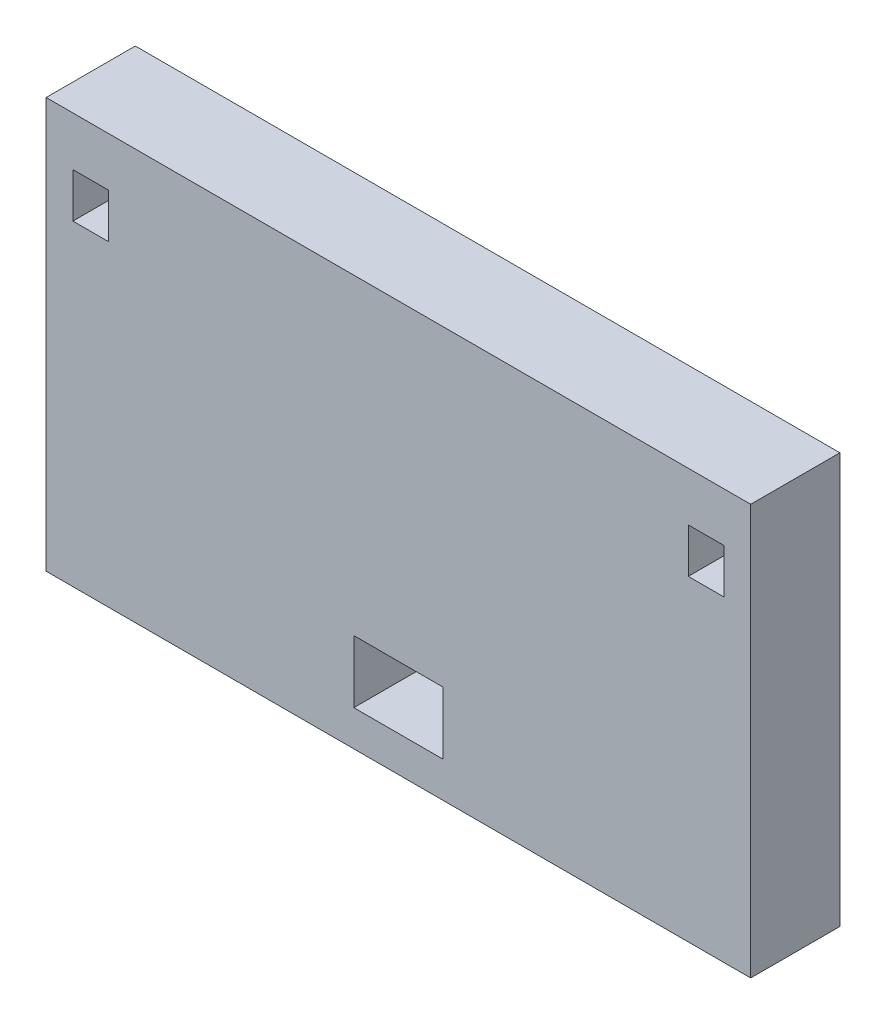
from build123d import *

# Parameters (mm, degrees)
SKETCH1_W           = 79
SKETCH1_H           = 46
SKETCH1_W_2         = 4
SKETCH1_H_2         = 5
SKETCH1_W_3         = 10
SKETCH1_H_3         = 7
BOSS_EXTRUDE1_DEPTH = 10


with BuildPart() as part:
    # Sketch1 → Boss-Extrude1 (new body)
    with BuildSketch(Plane.XY):
        with Locations((0, 20.611542264)):
            Rectangle(SKETCH1_W, SKETCH1_H)
        with Locations((-34.5, 35.611542264)):
            Rectangle(SKETCH1_W_2, SKETCH1_H_2, mode=Mode.SUBTRACT)
        with Locations((0, 5.111542264)):
            Rectangle(SKETCH1_W_3, SKETCH1_H_3, mode=Mode.SUBTRACT)
        with Locations((34.5, 35.611542264)):
            Rectangle(SKETCH1_W_2, SKETCH1_H_2, mode=Mode.SUBTRACT)
    extrude(amount=BOSS_EXTRUDE1_DEPTH)


solid = part.part
